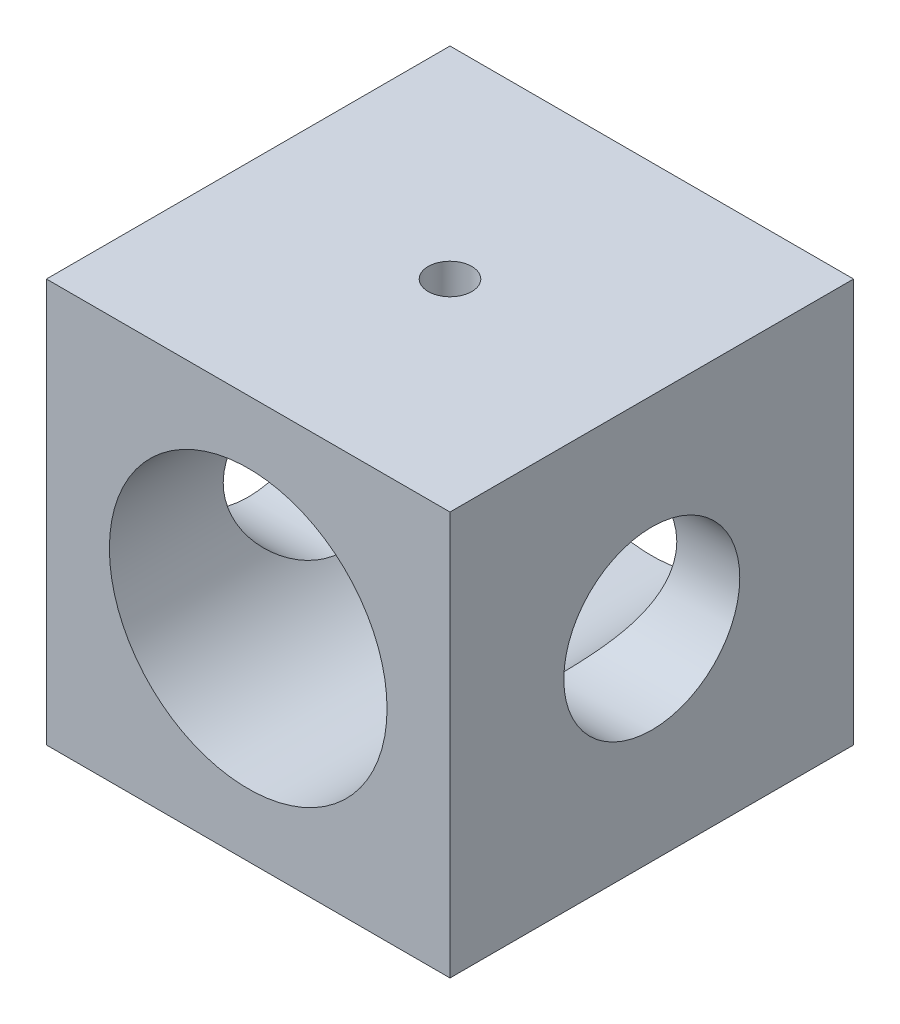
from build123d import *

# Parameters (mm, degrees)
SKETCH3_W           = 25
SKETCH3_H           = 25
BOSS_EXTRUDE1_DEPTH = 25
CUT_EXTRUDE1_REACH  = 27
SKETCH4_R           = 8.6
CUT_EXTRUDE2_REACH  = 27
SKETCH5_R           = 1.35
SKETCH6_R           = 5.45
CUT_EXTRUDE3_DEPTH  = 26


with BuildPart() as part:
    # Sketch3 → Boss-Extrude1 (new body)
    with BuildSketch(Plane(origin=(0, 0, 0), x_dir=(1, 0, 0), z_dir=(0, 1, 0))):
        Rectangle(SKETCH3_W, SKETCH3_H)
    extrude(amount=BOSS_EXTRUDE1_DEPTH)

    # Sketch4 → Cut-Extrude1 (cut, up to next)
    with BuildSketch(Plane.XY.offset(12.5), mode=Mode.PRIVATE) as cut_extrude1_sk1:
        with Locations((0, 12.5)):
            Circle(SKETCH4_R)
    cut_extrude1_tool1 = extrude(cut_extrude1_sk1.sketch, amount=-CUT_EXTRUDE1_REACH, mode=Mode.PRIVATE) & part.part
    add(cut_extrude1_tool1.solids().sort_by_distance((0, 12.5, 12.5))[0], mode=Mode.SUBTRACT)

    # Sketch5 → Cut-Extrude2 (cut, up to next)
    with BuildSketch(Plane(origin=(0, 25, 0), x_dir=(1, 0, 0), z_dir=(0, 1, 0)), mode=Mode.PRIVATE) as cut_extrude2_sk1:
        Circle(SKETCH5_R)
    cut_extrude2_tool1 = extrude(cut_extrude2_sk1.sketch, amount=-CUT_EXTRUDE2_REACH, mode=Mode.PRIVATE) & part.part
    add(cut_extrude2_tool1.solids().sort_by_distance((0, 25, 0))[0], mode=Mode.SUBTRACT)

    # Sketch6 → Cut-Extrude3 (cut, through all)
    with BuildSketch(Plane.ZY.offset(12.5)):
        with Locations((0, 12.5)):
            Circle(SKETCH6_R)
    extrude(amount=-CUT_EXTRUDE3_DEPTH, mode=Mode.SUBTRACT)


solid = part.part
